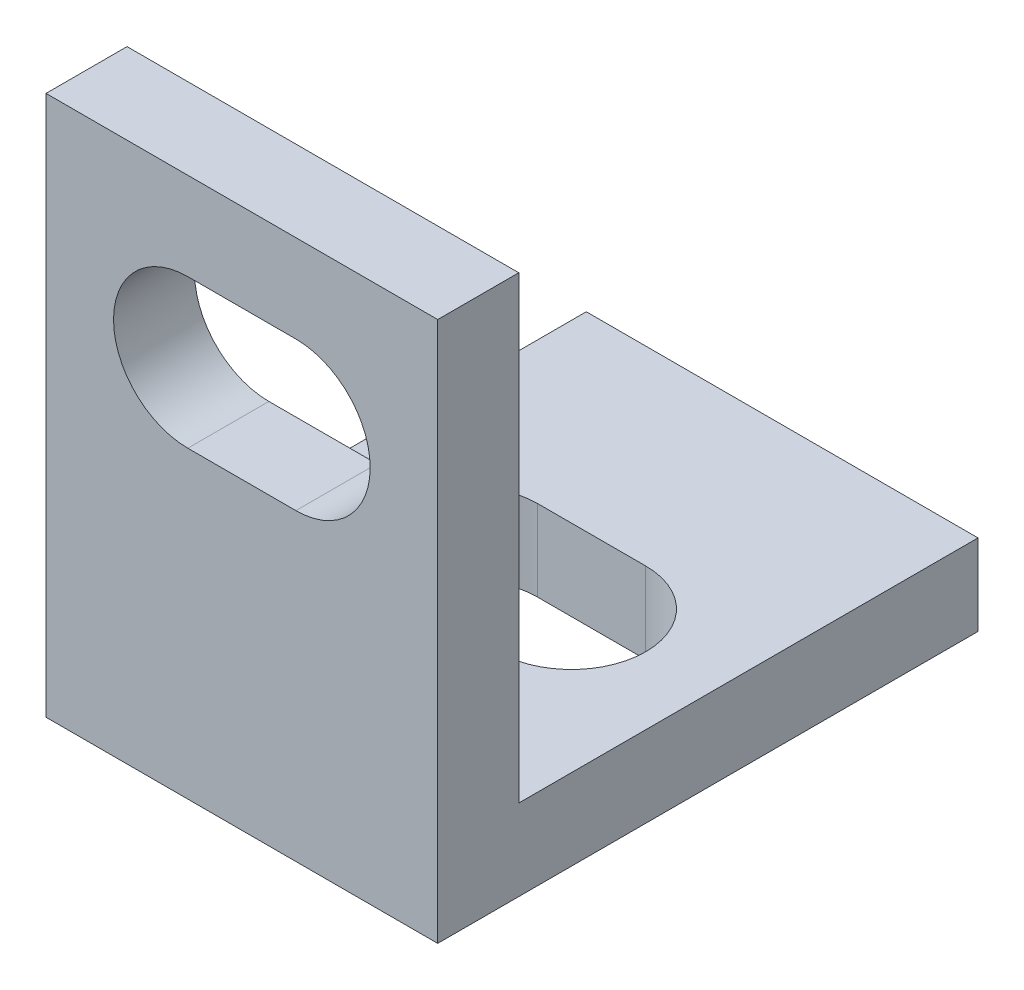
from build123d import *

# Parameters (mm, degrees)
BOSS_EXTRUDE1_DEPTH = 14.5
CUT_EXTRUDE1_DEPTH  = 21
CUT_EXTRUDE2_DEPTH  = 21


with BuildPart() as part:
    # Sketch1 → Boss-Extrude1 (new body)
    with BuildSketch(Plane(origin=(0, 0, 0), x_dir=(0, 0, -1), z_dir=(1, 0, 0))):
        Polygon((0, 0), (0, 20), (3, 20), (3, 3), (20, 3), (20, 0), align=None)
    extrude(amount=BOSS_EXTRUDE1_DEPTH)

    # Sketch2 → Cut-Extrude1 (cut, through all)
    with BuildSketch(Plane.XY):
        with BuildLine():
            Line((5.25, 16.75), (9.25, 16.75))
            ThreePointArc((9.25, 16.75), (12, 14), (9.25, 11.25))
            Line((9.25, 11.25), (5.25, 11.25))
            ThreePointArc((5.25, 11.25), (2.5, 14), (5.25, 16.75))
        make_face()
    extrude(amount=-CUT_EXTRUDE1_DEPTH, mode=Mode.SUBTRACT)

    # Sketch3 → Cut-Extrude2 (cut, through all)
    with BuildSketch(Plane.XZ):
        with BuildLine():
            Line((5.25, -7.45), (9.25, -7.45))
            ThreePointArc((9.25, -7.45), (12, -10.2), (9.25, -12.95))
            Line((9.25, -12.95), (5.25, -12.95))
            ThreePointArc((5.25, -12.95), (2.5, -10.2), (5.25, -7.45))
        make_face()
    extrude(amount=-CUT_EXTRUDE2_DEPTH, mode=Mode.SUBTRACT)


solid = part.part
